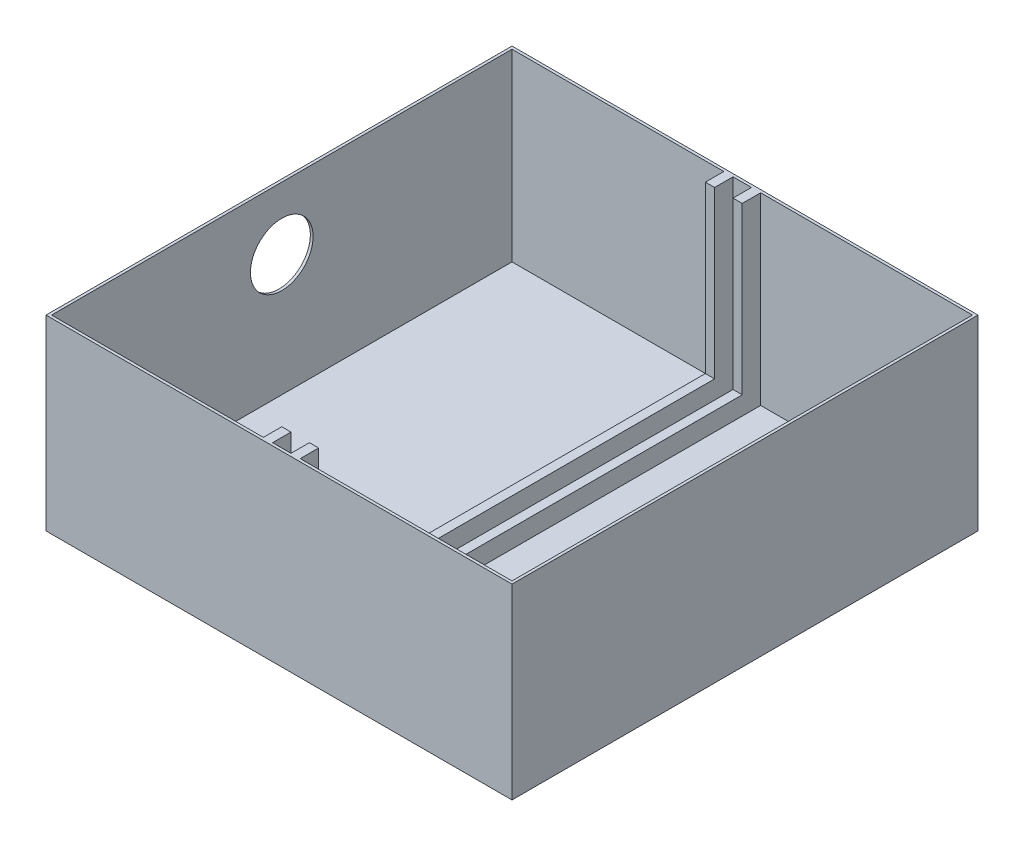
from build123d import *

# Parameters (mm, degrees)
SKETCH1_W           = 253
SKETCH1_H           = 253
BOSS_EXTRUDE1_DEPTH = 101.5
SHELL2_T            = -1.5
SKETCH2_W           = 5
SKETCH2_H           = 230
BOSS_EXTRUDE3_DEPTH = 10
SKETCH3_W           = 5
SKETCH3_H           = 10
BOSS_EXTRUDE4_DEPTH = 100
SKETCH4_R           = 17
CUT_EXTRUDE1_DEPTH  = 1.5


with BuildPart() as part:
    # Sketch1 → Boss-Extrude1 (new body)
    with BuildSketch(Plane(origin=(0, 0, 0), x_dir=(1, 0, 0), z_dir=(0, 1, 0))):
        Rectangle(SKETCH1_W, SKETCH1_H)
    extrude(amount=BOSS_EXTRUDE1_DEPTH)

    # Shell2
    shell2_openings = [part.faces().sort_by_distance(p)[0] for p in [
        (0, 101.5, 0),
    ]]
    offset(amount=SHELL2_T, openings=shell2_openings, kind=Kind.INTERSECTION)

    # Sketch2 → Boss-Extrude3 (add)
    with BuildSketch(Plane(origin=(0, 1.5, 0), x_dir=(1, 0, 0), z_dir=(0, 1, 0))):
        with Locations((-7.5, 0)):
            Rectangle(SKETCH2_W, SKETCH2_H)
        with Locations((7.5, 0)):
            Rectangle(SKETCH2_W, SKETCH2_H)
    extrude(amount=BOSS_EXTRUDE3_DEPTH)

    # Sketch3 → Boss-Extrude4 (add)
    with BuildSketch(Plane(origin=(0, 1.5, 0), x_dir=(1, 0, 0), z_dir=(0, 1, 0))):
        with Locations((-7.5, 120)):
            Rectangle(SKETCH3_W, SKETCH3_H)
        with Locations((7.5, 120)):
            Rectangle(SKETCH3_W, SKETCH3_H)
        with Locations((7.5, -120)):
            Rectangle(SKETCH3_W, SKETCH3_H)
        with Locations((-7.5, -120)):
            Rectangle(SKETCH3_W, SKETCH3_H)
    extrude(amount=BOSS_EXTRUDE4_DEPTH)

    # Sketch4 → Cut-Extrude1 (cut)
    with BuildSketch(Plane.ZY.offset(126.5)):
        with Locations((0, 67.5)):
            Circle(SKETCH4_R)
    extrude(amount=-CUT_EXTRUDE1_DEPTH, mode=Mode.SUBTRACT)


solid = part.part
